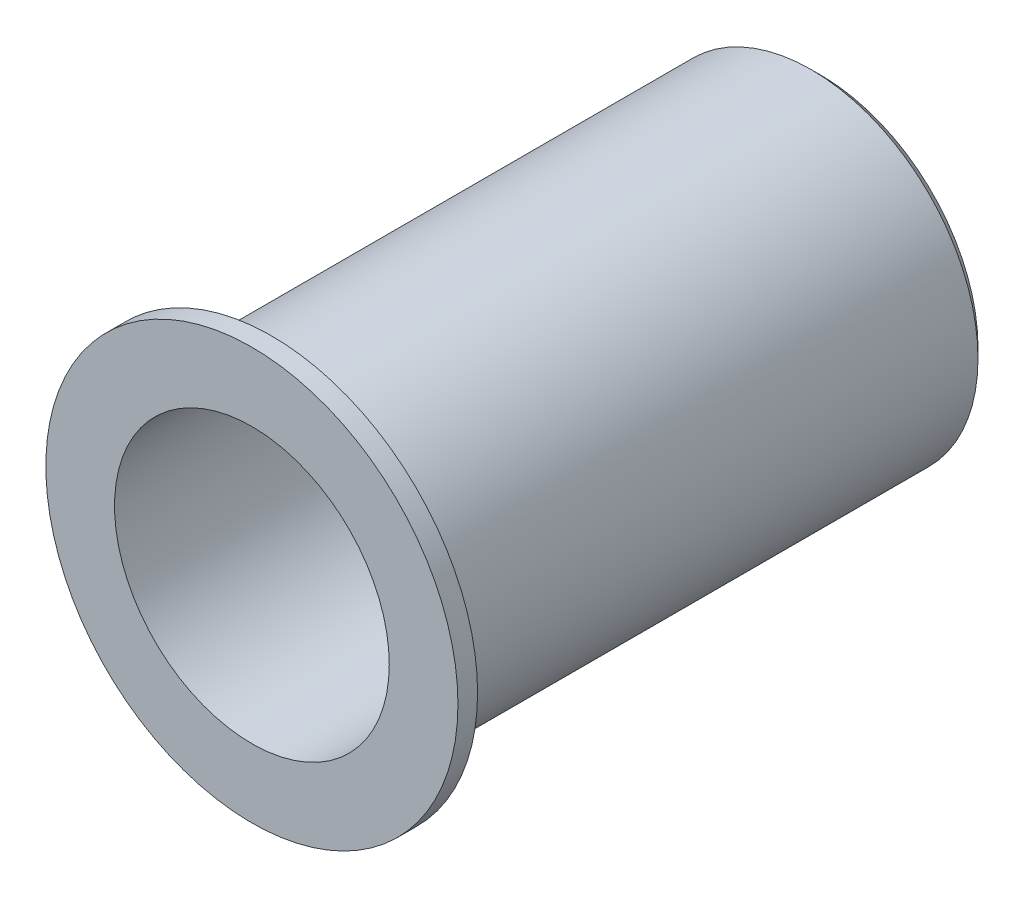
from build123d import *

# Parameters (mm, degrees)
SKETCH_1_R          = 8.5
EXTRUDE_1_DEPTH     = 28
SKETCH_2_R          = 7
CUT_EXTRUDE_3_DEPTH = 23
HOLE_WIZARD_M4_1_D  = 3.3
SKETCH_10_R         = 10.5
SKETCH_10_R_2       = 8.5
SKETCH_10_R_3       = 7
EXTRUDE_4_DEPTH     = 1
CHAMFER_1_SIZE      = 0.5


with BuildPart() as part:
    # 草图1 → 凸台-拉伸1 (new body)
    with BuildSketch(Plane.XY):
        Circle(SKETCH_1_R)
    extrude(amount=EXTRUDE_1_DEPTH)

    # 草图2 → 切除-拉伸3 (cut)
    with BuildSketch(Plane.XY.offset(28)):
        Circle(SKETCH_2_R)
    extrude(amount=-CUT_EXTRUDE_3_DEPTH, mode=Mode.SUBTRACT)

    # M4 螺纹孔1 (through all)
    with Locations(Plane(origin=(0, 0, 0), x_dir=(-1, 0, 0), z_dir=(0, 0, -1))):
        with Locations((0, 5), (0, 0), (-4.330127019, -2.5), (4.330127019, -2.5)):
            Hole(HOLE_WIZARD_M4_1_D / 2)

    # 草图10 → 凸台-拉伸4 (add)
    with BuildSketch(Plane.XY.offset(28)):
        Circle(SKETCH_10_R)
        Circle(SKETCH_10_R_2, mode=Mode.SUBTRACT)
        Circle(SKETCH_10_R_2)
        Circle(SKETCH_10_R_3, mode=Mode.SUBTRACT)
    extrude(amount=EXTRUDE_4_DEPTH)

    # 倒角1
    chamfer_1_edges = [part.edges().sort_by_distance(p)[0] for p in [
        (-8.5, 0, 0),
    ]]
    chamfer(chamfer_1_edges, length=CHAMFER_1_SIZE)


solid = part.part
